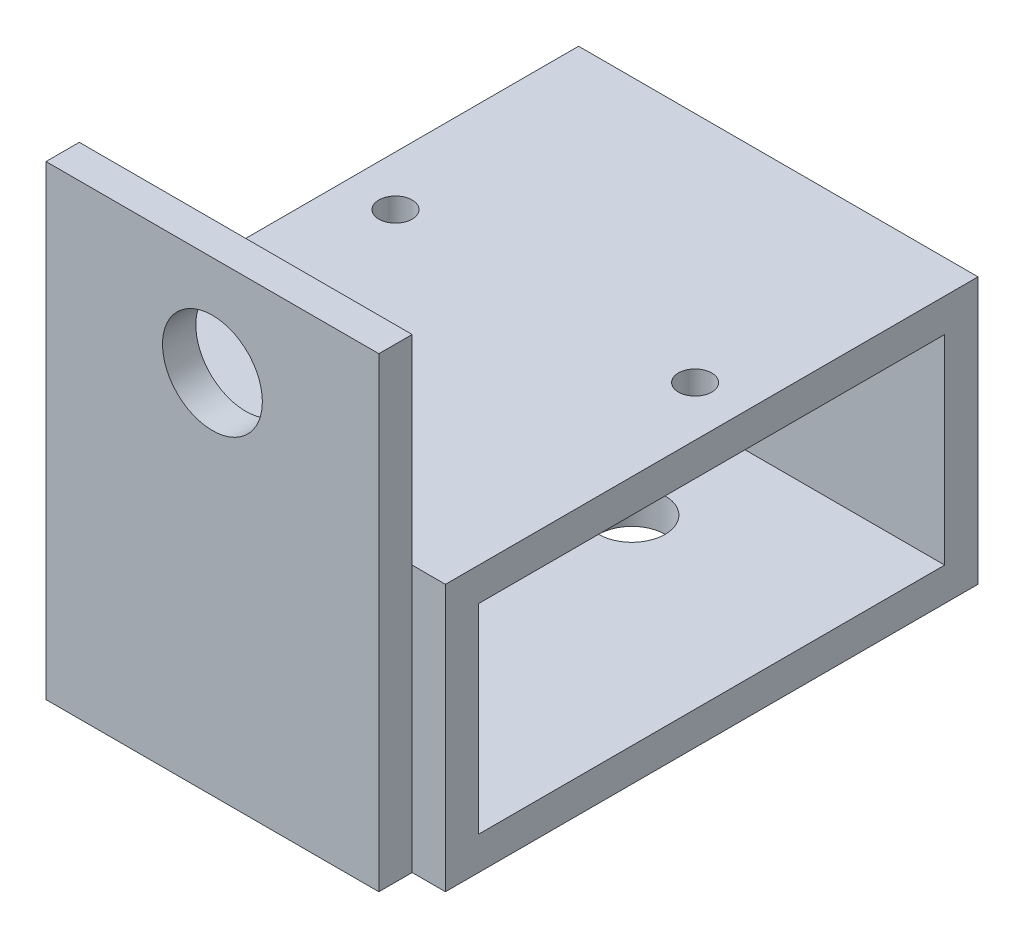
from build123d import *

# Parameters (mm, degrees)
SKETCH1_W           = 50.8
SKETCH1_H           = 25.4
SKETCH1_W_2         = 44.45
SKETCH1_H_2         = 19.05
EXTRUDE_THIN1_DEPTH = 19.05
SKETCH2_W           = 31.75
SKETCH2_H           = 3.175
BOSS_EXTRUDE1_DEPTH = 44.45
CUT_EXTRUDE1_REACH  = 55.975
SKETCH3_R           = 4.7625
CUT_EXTRUDE2_REACH  = 27.4
SKETCH4_R           = 1.5875
SKETCH8_R           = 3.175
CUT_EXTRUDE4_DEPTH  = 3.175


with BuildPart() as part:
    # Sketch1 → Extrude-Thin1 (new body, symmetric)
    with BuildSketch(Plane(origin=(0, 0, 0), x_dir=(0, 0, -1), z_dir=(1, 0, 0))):
        Rectangle(SKETCH1_W, SKETCH1_H)
        Rectangle(SKETCH1_W_2, SKETCH1_H_2, mode=Mode.SUBTRACT)
    extrude(amount=EXTRUDE_THIN1_DEPTH, both=True)

    # Sketch2 → Boss-Extrude1 (add)
    with BuildSketch(Plane.XZ.offset(12.7)):
        with Locations((0, 26.9875)):
            Rectangle(SKETCH2_W, SKETCH2_H)
    extrude(amount=-BOSS_EXTRUDE1_DEPTH)

    # Sketch3 → Cut-Extrude1 (cut, up to next)
    with BuildSketch(Plane.XY.offset(28.575), mode=Mode.PRIVATE) as cut_extrude1_sk1:
        with Locations((0, 22.225)):
            Circle(SKETCH3_R)
    cut_extrude1_tool1 = extrude(cut_extrude1_sk1.sketch, amount=-CUT_EXTRUDE1_REACH, mode=Mode.PRIVATE) & part.part
    add(cut_extrude1_tool1.solids().sort_by_distance((0, 22.225, 28.575))[0], mode=Mode.SUBTRACT)

    # Sketch4 → Cut-Extrude2 (cut, up to next)
    with BuildSketch(Plane(origin=(0, 12.7, 0), x_dir=(1, 0, 0), z_dir=(0, 1, 0)), mode=Mode.PRIVATE) as cut_extrude2_sk1:
        with Locations((14.2875, 3.175)):
            Circle(SKETCH4_R)
    cut_extrude2_tool1 = extrude(cut_extrude2_sk1.sketch, amount=-CUT_EXTRUDE2_REACH, mode=Mode.PRIVATE) & part.part
    add(cut_extrude2_tool1.solids().sort_by_distance((14.2875, 12.7, -3.175))[0], mode=Mode.SUBTRACT)
    # Sketch4 → Cut-Extrude2 (cut, up to next)
    with BuildSketch(Plane(origin=(0, 12.7, 0), x_dir=(1, 0, 0), z_dir=(0, 1, 0)), mode=Mode.PRIVATE) as cut_extrude2_sk2:
        with Locations((-14.2875, 3.175)):
            Circle(SKETCH4_R)
    cut_extrude2_tool2 = extrude(cut_extrude2_sk2.sketch, amount=-CUT_EXTRUDE2_REACH, mode=Mode.PRIVATE) & part.part
    add(cut_extrude2_tool2.solids().sort_by_distance((-14.2875, 12.7, -3.175))[0], mode=Mode.SUBTRACT)

    # Sketch8 → Cut-Extrude4 (cut)
    with BuildSketch(Plane.XZ.offset(12.7)):
        with Locations((0, -11.43)):
            Circle(SKETCH8_R)
        with Locations((0, 11.43)):
            Circle(SKETCH8_R)
    extrude(amount=-CUT_EXTRUDE4_DEPTH, mode=Mode.SUBTRACT)


solid = part.part
